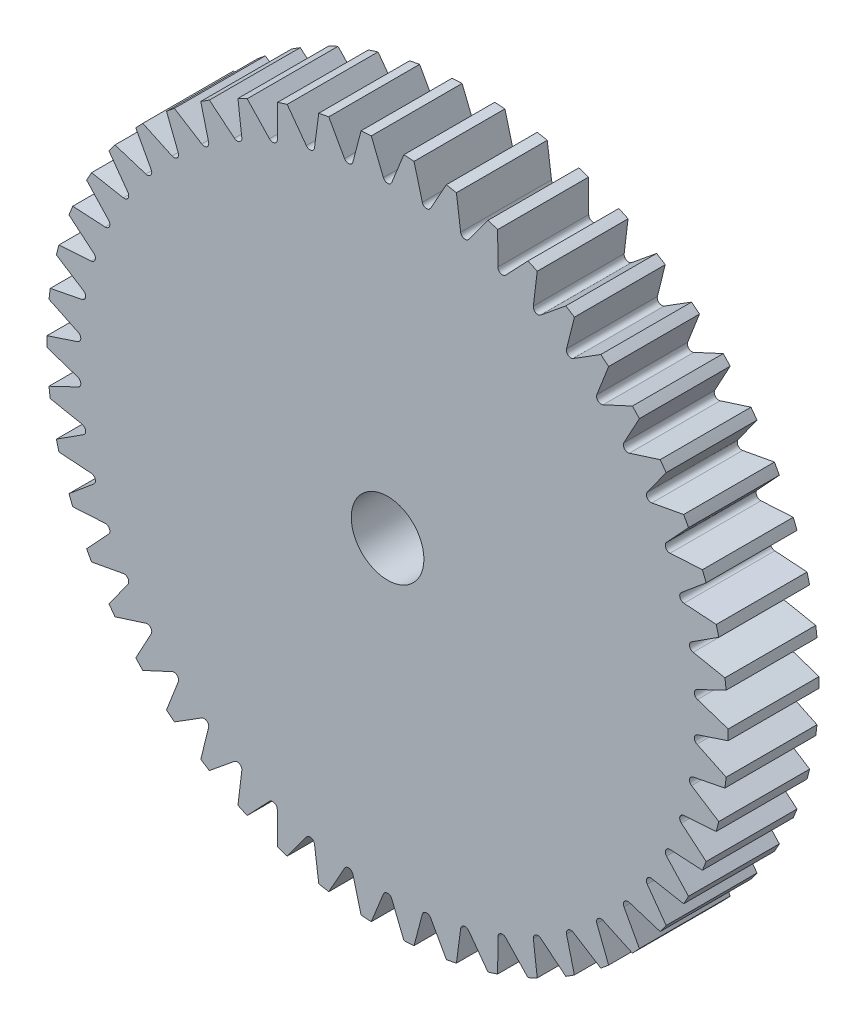
from build123d import *

# Parameters (mm, degrees)
SKETCH1_R           = 37.5
SKETCH1_R_2         = 4
BOSS_EXTRUDE1_DEPTH = 10
CUT_EXTRUDE1_DEPTH  = 11
CIRPATTERN1_COUNT   = 50


with BuildPart() as part:
    # Sketch1 → Boss-Extrude1 (new body)
    with BuildSketch(Plane.XY):
        Circle(SKETCH1_R)
        Circle(SKETCH1_R_2, mode=Mode.SUBTRACT)
    extrude(amount=BOSS_EXTRUDE1_DEPTH)

    # Sketch2 → Cut-Extrude1 (cut, through all)
    with BuildSketch(Plane.XY.offset(10)):
        with BuildLine():
            Line((-3.840395579, 42.539457832), (-0.463824544, 34.152129928))
            ThreePointArc((-0.463824544, 34.152129928), (0, 33.838856445), (0.463824544, 34.152129928))
            Line((0.463824544, 34.152129928), (3.840395579, 42.539457832))
            Line((3.840395579, 42.539457832), (-3.840395579, 42.539457832))
        make_face()
    cut_extrude1 = extrude(amount=-CUT_EXTRUDE1_DEPTH, mode=Mode.SUBTRACT)

    # CirPattern1: Cut-Extrude1 ×50 about axis
    cirpattern1_axis = Axis((0, 0, 0), (0, 0, 1))
    for i in range(1, CIRPATTERN1_COUNT):
        add(cut_extrude1.rotate(cirpattern1_axis, i * 360 / CIRPATTERN1_COUNT), mode=Mode.SUBTRACT)


solid = part.part
